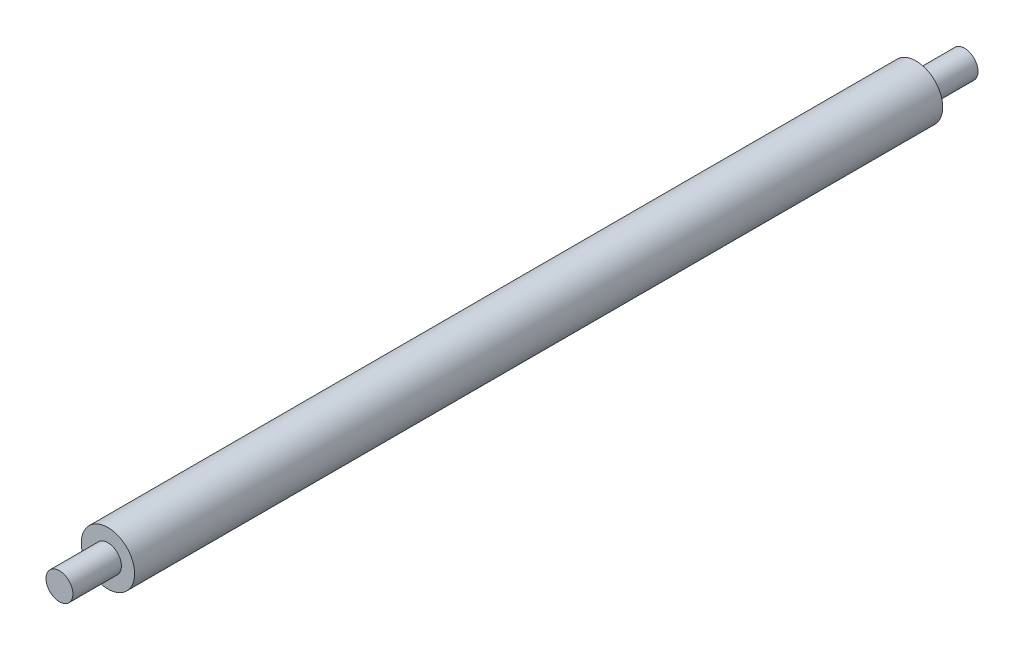
from build123d import *

# Parameters (mm, degrees)
SKETCH1_R                = 24.75
SKETCH1_R_2              = 21.75
BOSS_EXTRUDE1_DEPTH      = 750
SKETCH2_R                = 21.75
SKETCH2_R_2              = 12.5
BOSS_EXTRUDE2_DEPTH      = 5
SKETCH3_R                = 21.75
SKETCH3_R_2              = 12.5
BOSS_EXTRUDE3_DEPTH      = 5
SKETCH4_R                = 12.5
BOSS_EXTRUDE4_DEPTH      = 45
BOSS_EXTRUDE4_DEPTH_BACK = 5
SKETCH5_R                = 12.5
BOSS_EXTRUDE5_DEPTH      = 45
BOSS_EXTRUDE5_DEPTH_BACK = 5


with BuildPart() as part:
    # Sketch1 → Boss-Extrude1 (new body)
    with BuildSketch(Plane.XY):
        Circle(SKETCH1_R)
        Circle(SKETCH1_R_2, mode=Mode.SUBTRACT)
    extrude(amount=BOSS_EXTRUDE1_DEPTH)

    # Sketch2 → Boss-Extrude2 (add)
    with BuildSketch(Plane.XY):
        Circle(SKETCH2_R)
        Circle(SKETCH2_R_2, mode=Mode.SUBTRACT)
    extrude(amount=BOSS_EXTRUDE2_DEPTH)

    # Sketch3 → Boss-Extrude3 (add)
    with BuildSketch(Plane.XY.offset(750)):
        Circle(SKETCH3_R)
        Circle(SKETCH3_R_2, mode=Mode.SUBTRACT)
    extrude(amount=-BOSS_EXTRUDE3_DEPTH)

    # Sketch4 → Boss-Extrude4 (add, two sides)
    with BuildSketch(Plane.XY.offset(750)) as boss_extrude4_sk:
        Circle(SKETCH4_R)
    extrude(amount=BOSS_EXTRUDE4_DEPTH)
    extrude(boss_extrude4_sk.sketch, amount=-BOSS_EXTRUDE4_DEPTH_BACK)

    # Sketch5 → Boss-Extrude5 (add, two sides)
    with BuildSketch(Plane(origin=(0, 0, 0), x_dir=(-1, 0, 0), z_dir=(0, 0, -1))) as boss_extrude5_sk:
        Circle(SKETCH5_R)
    extrude(amount=BOSS_EXTRUDE5_DEPTH)
    extrude(boss_extrude5_sk.sketch, amount=-BOSS_EXTRUDE5_DEPTH_BACK)


solid = part.part
